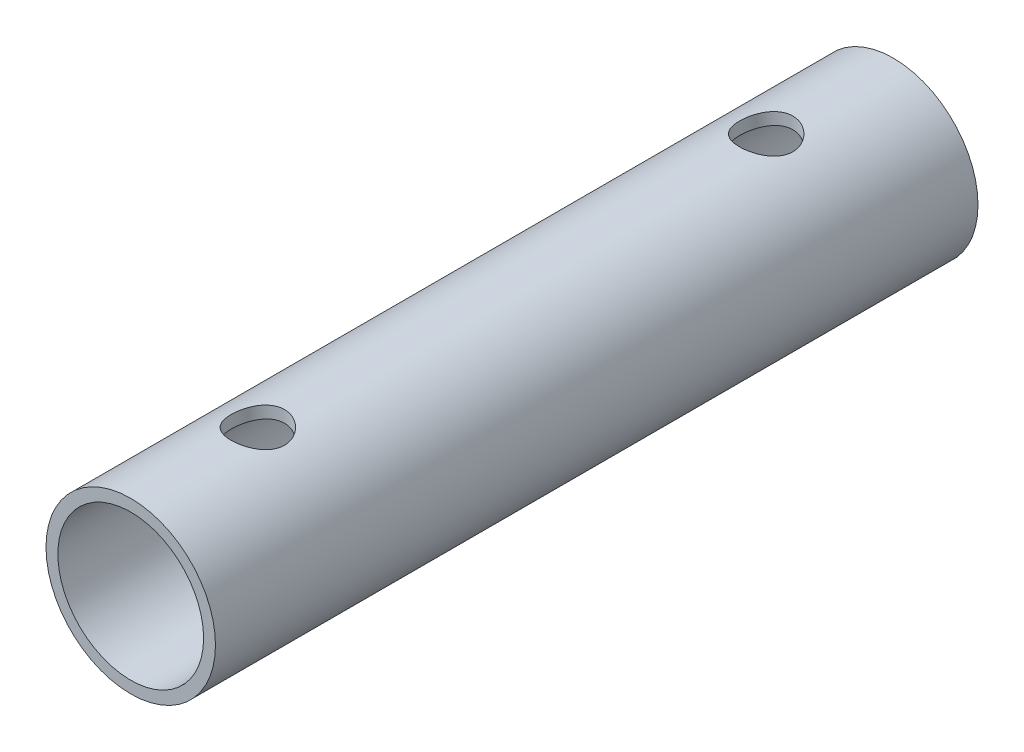
from build123d import *

# Parameters (mm, degrees)
SKETCH1_R               = 6.35
SKETCH1_R_2             = 5.461
EXTRUDE1_DEPTH          = 57.15
SKETCH2_R               = 2
CUT_EXTRUDE1_DEPTH      = 38.1
CUT_EXTRUDE1_DEPTH_BACK = 38.1


with BuildPart() as part:
    # Sketch1 → Extrude1 (new body)
    with BuildSketch(Plane.XY):
        Circle(SKETCH1_R)
        Circle(SKETCH1_R_2, mode=Mode.SUBTRACT)
    extrude(amount=EXTRUDE1_DEPTH)

    # Sketch2 → Cut-Extrude1 (cut, two sides)
    with BuildSketch(Plane(origin=(0, 0, 0), x_dir=(1, 0, 0), z_dir=(0, 1, 0))) as cut_extrude1_sk:
        with Locations(Location((0, -9.525, 0), (0, 0, 270))):  # turned: the seam where the file's is
            Circle(SKETCH2_R)
        with Locations(Location((0, -47.625, 0), (0, 0, 270))):  # turned: the seam where the file's is
            Circle(SKETCH2_R)
    extrude(amount=CUT_EXTRUDE1_DEPTH, mode=Mode.SUBTRACT)
    extrude(cut_extrude1_sk.sketch, amount=-CUT_EXTRUDE1_DEPTH_BACK, mode=Mode.SUBTRACT)


solid = part.part
